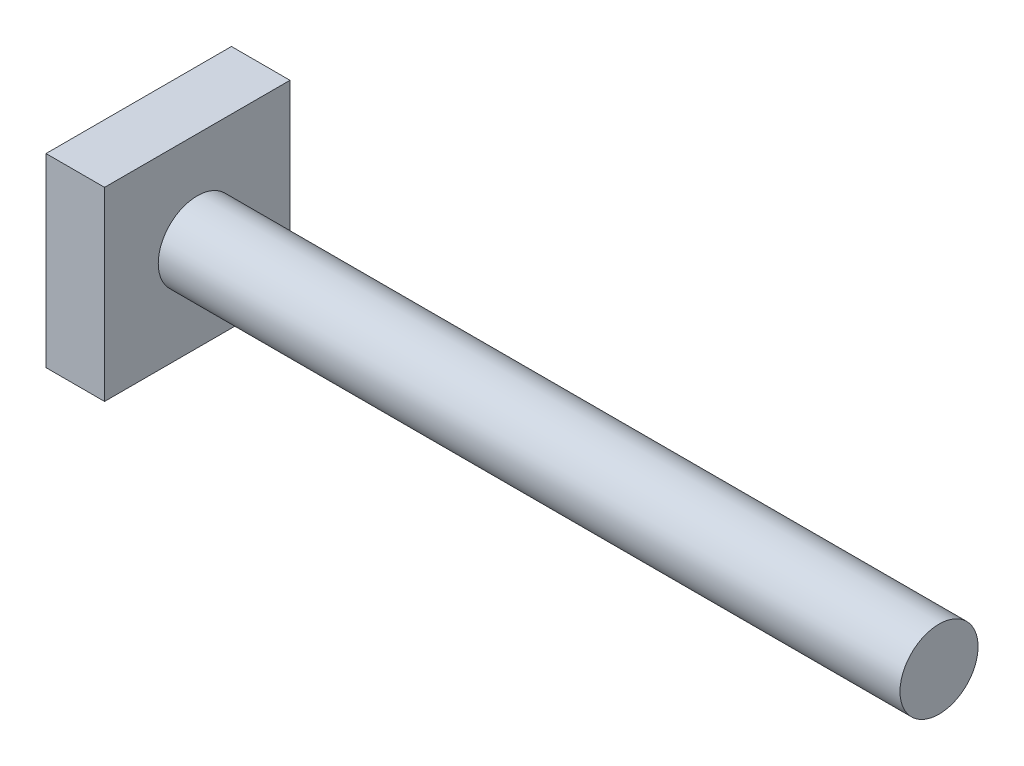
from build123d import *

# Parameters (mm, degrees)
SKETCH1_W           = 76
SKETCH1_H           = 4
SKETCH2_W           = 19
SKETCH2_H           = 19
BOSS_EXTRUDE1_DEPTH = 6


with BuildPart() as part:
    # Sketch1 → Revolve1 (revolve)
    with BuildSketch(Plane.XY, mode=Mode.PRIVATE) as revolve1_sk:
        with Locations((38, 2)):
            Rectangle(SKETCH1_W, SKETCH1_H)
    revolve(revolve1_sk.sketch.rotate(Axis((0, 0, 0), (1, 0, 0)), 90), axis=Axis((0, 0, 0), (1, 0, 0)))  # turned: the seam where the file's is

    # Sketch2 → Boss-Extrude1 (add)
    with BuildSketch(Plane.ZY):
        Rectangle(SKETCH2_W, SKETCH2_H)
    extrude(amount=BOSS_EXTRUDE1_DEPTH)


solid = part.part
